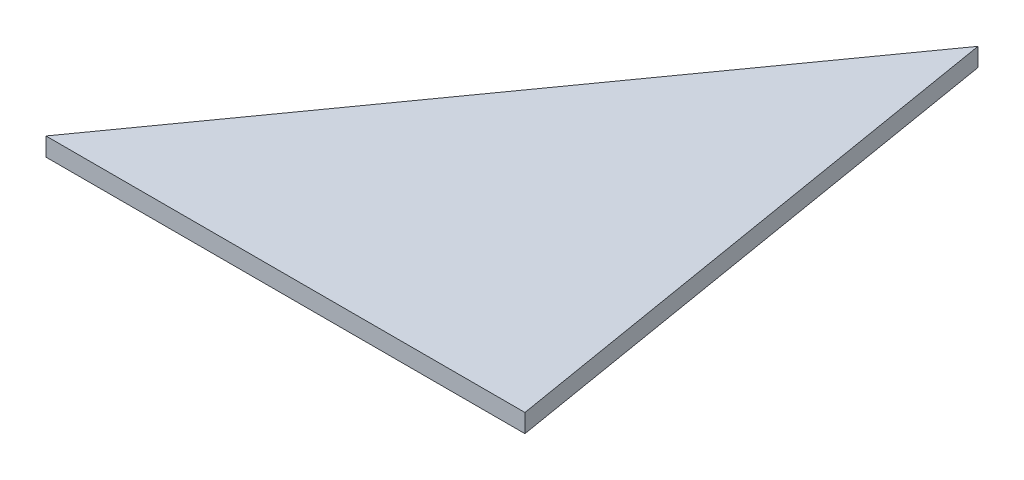
from build123d import *

# Parameters (mm, degrees)
BOSS_EXTRU_1_DEPTH = 2


with BuildPart() as part:
    # Esquisse1 → Boss.-Extru.1 (new body)
    with BuildSketch(Plane(origin=(0, 0, 0), x_dir=(1, 0, 0), z_dir=(0, 1, 0))):
        Polygon((0, 0), (52.140487741, 0), (42.280557975, 59.184303536), align=None)
    extrude(amount=BOSS_EXTRU_1_DEPTH)


solid = part.part
